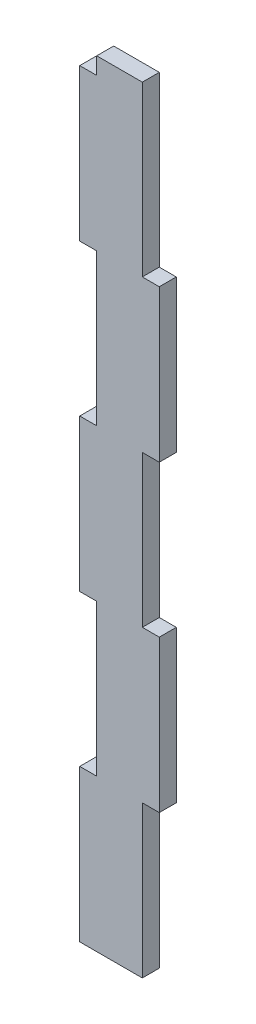
from build123d import *

# Parameters (mm, degrees)
BOSS_EXTRUDE1_DEPTH = 5.4
BOSS_EXTRUDE2_DEPTH = 5.4


with BuildPart() as part:
    # Sketch1 → Boss-Extrude1 (new body)
    with BuildSketch(Plane.XY):
        Polygon((-239.303382108, -8.567555325), (-239.303382108, -13.967555325), (-244.703382108, -13.967555325), (-244.703382108, -62.232555325), (-239.303382108, -62.232555325), (-239.303382108, -110.497555325), (-244.703382108, -110.497555325), (-244.703382108, -158.762555325), (-239.303382108, -158.762555325), (-239.303382108, -207.027555325), (-244.703382108, -207.027555325), (-244.703382108, -255.292555325), (-224.878382108, -255.292555325), (-224.878382108, -207.027555325), (-219.478382108, -207.027555325), (-219.478382108, -158.762555325), (-224.878382108, -158.762555325), (-224.878382108, -110.497555325), (-219.478382108, -110.497555325), (-219.478382108, -62.232555325), (-224.878382108, -62.232555325), (-224.878382108, -8.567555325), align=None)
    extrude(amount=BOSS_EXTRUDE1_DEPTH)

    # Sketch2 → Boss-Extrude2 (add)
    with BuildSketch(Plane.XY.offset(5.4)):
        Polygon((-239.344022108, -8.526915325), (-239.344022108, -13.926915325), (-244.744022108, -13.926915325), (-244.744022108, -62.273195325), (-239.344022108, -62.273195325), (-239.344022108, -110.456915325), (-244.744022108, -110.456915325), (-244.744022108, -158.803195325), (-239.344022108, -158.803195325), (-239.344022108, -206.986915325), (-244.744022108, -206.986915325), (-244.744022108, -255.333195325), (-224.837742108, -255.333195325), (-224.837742108, -207.068195325), (-219.437742108, -207.068195325), (-219.437742108, -158.721915325), (-224.837742108, -158.721915325), (-224.837742108, -110.538195325), (-219.437742108, -110.538195325), (-219.437742108, -62.191915325), (-224.837742108, -62.191915325), (-224.837742108, -8.526915325), align=None)
    extrude(amount=-BOSS_EXTRUDE2_DEPTH)


solid = part.part
